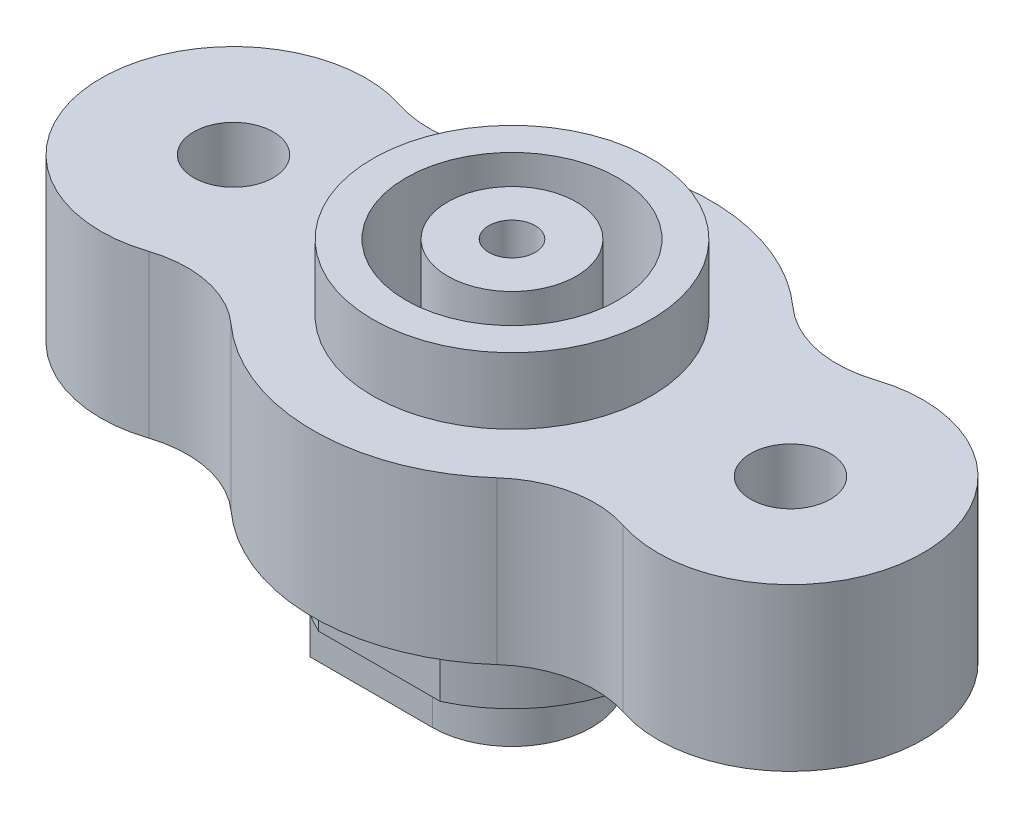
from build123d import *

# Parameters (mm, degrees)
SKETCH1_R           = 7.5
SKETCH1_R_2         = 5
SKETCH1_R_3         = 1.5
BOSS_EXTRUDE1_DEPTH = 6.1
SKETCH2_R           = 5.25
BOSS_EXTRUDE2_DEPTH = 2.5
BOSS_EXTRUDE3_DEPTH = 2.85
SKETCH3_R           = 4
SKETCH3_R_2         = 2.425
SKETCH3_R_3         = 0.875
CUT_EXTRUDE1_DEPTH  = 8
FILLET1_R           = 4
SKETCH5_R           = 3
BOSS_EXTRUDE4_DEPTH = 3


with BuildPart() as part:
    # Sketch1 → Boss-Extrude1 (new body)
    with BuildSketch(Plane(origin=(0, 0, 0), x_dir=(1, 0, 0), z_dir=(0, 1, 0))):
        Circle(SKETCH1_R)
        with Locations((-10.5, 0)):
            Circle(SKETCH1_R_2)
        with Locations((-10.5, 0)):
            Circle(SKETCH1_R_3, mode=Mode.SUBTRACT)
        with Locations((10.5, 0)):
            Circle(SKETCH1_R_2)
        with Locations((10.5, 0)):
            Circle(SKETCH1_R_3, mode=Mode.SUBTRACT)
    extrude(amount=BOSS_EXTRUDE1_DEPTH)

    # Sketch2 → Boss-Extrude2 (add)
    with BuildSketch(Plane(origin=(0, 6.1, 0), x_dir=(1, 0, 0), z_dir=(0, 1, 0))):
        Circle(SKETCH2_R)
    extrude(amount=BOSS_EXTRUDE2_DEPTH)

    # Sketch4 → Boss-Extrude3 (add)
    with BuildSketch(Plane.XZ):
        with BuildLine():
            Line((-2.291287847, -5), (2.291287847, -5))
            ThreePointArc((2.291287847, -5), (4.628827236, -2.970514841), (5.5, 0))
            ThreePointArc((5.5, 0), (4.628827236, 2.970514841), (2.291287847, 5))
            Line((2.291287847, 5), (-2.291287847, 5))
            ThreePointArc((-2.291287847, 5), (-4.628827236, 2.970514841), (-5.5, 0))
            ThreePointArc((-5.5, 0), (-4.628827236, -2.970514841), (-2.291287847, -5))
        make_face()
    extrude(amount=BOSS_EXTRUDE3_DEPTH)

    # Sketch3 → Cut-Extrude1 (cut)
    with BuildSketch(Plane(origin=(0, 8.6, 0), x_dir=(1, 0, 0), z_dir=(0, 1, 0))):
        Circle(SKETCH3_R)
        Circle(SKETCH3_R_2, mode=Mode.SUBTRACT)
        Circle(SKETCH3_R_3)
    extrude(amount=-CUT_EXTRUDE1_DEPTH, mode=Mode.SUBTRACT)

    # Fillet1
    fillet1_edges = [part.edges().sort_by_distance(p)[0] for p in [
        (-6.738095238, 3.05, -3.293641232),
        (6.738095238, 3.05, -3.293641232),
        (6.738095238, 3.05, 3.293641232),
        (-6.738095238, 3.05, 3.293641232),
    ]]
    fillet(fillet1_edges, radius=FILLET1_R)

    # Sketch5 → Boss-Extrude4 (add)
    with BuildSketch(Plane.XZ.offset(2.85)):
        Circle(SKETCH5_R)
        with BuildLine():
            ThreePointArc((0, -3), (-3, 0), (0, 3))
            Line((0, 3), (-4.609772229, 3))
            ThreePointArc((-4.609772229, 3), (-5.5, 0), (-4.609772229, -3))
            Line((-4.609772229, -3), (0, -3))
        make_face()
    extrude(amount=BOSS_EXTRUDE4_DEPTH)


solid = part.part
